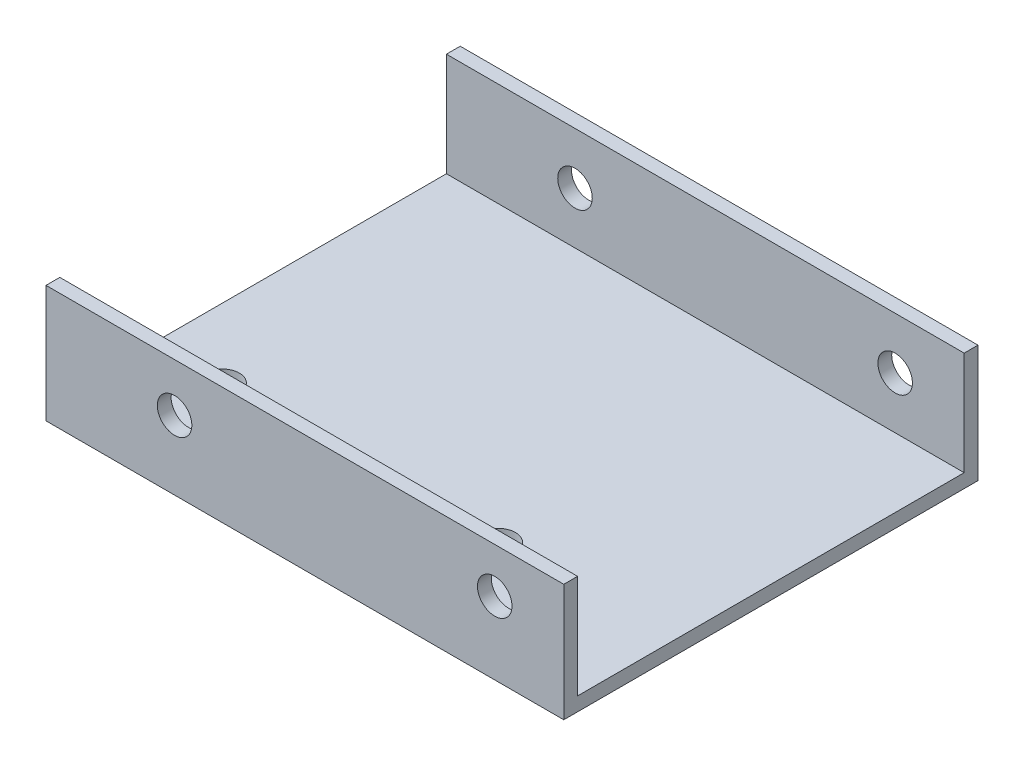
from build123d import *

# Parameters (mm, degrees)
ESBO_O1_W                = 75
ESBO_O1_H                = 56
RESSALTO_EXTRUS_O1_DEPTH = 2
ESBO_O3_W                = 75
ESBO_O3_H                = 17
RESSALTO_EXTRUS_O3_DEPTH = 2
CORTE_EXTRUS_O1_REACH    = 72
ESBO_O4_R                = 2.5
CORTE_EXTRUS_O2_REACH    = 62
ESBO_O5_R                = 2.5
ESBO_O6_R                = 2.5
CORTE_EXTRUS_O3_DEPTH    = 2
CUT_EXTRUDE1_REACH       = 62
SKETCH1_R                = 2.5
CUT_EXTRUDE2_REACH       = 62
SKETCH2_R                = 2.5


with BuildPart() as part:
    # Esboço1 → Ressalto-extrusão1 (new body)
    with BuildSketch(Plane(origin=(0, 0, 0), x_dir=(1, 0, 0), z_dir=(0, 1, 0))):
        Rectangle(ESBO_O1_W, ESBO_O1_H)
    extrude(amount=RESSALTO_EXTRUS_O1_DEPTH)

    # Esboço3 → Ressalto-extrusão3 (add)
    with BuildSketch(Plane.XY.offset(28)):
        with Locations((0, 8.5)):
            Rectangle(ESBO_O3_W, ESBO_O3_H)
    ressalto_extrus_o3 = extrude(amount=RESSALTO_EXTRUS_O3_DEPTH)

    # Espelhar2: Ressalto-extrusão3 across plane
    add(ressalto_extrus_o3.mirror(Plane.XY))

    # Esboço4 → Corte-extrusão1 (cut, up to next)
    with BuildSketch(Plane.XY.offset(40), mode=Mode.PRIVATE) as corte_extrus_o1_sk1:
        with Locations((-18.875, 10)):
            Circle(ESBO_O4_R)
    corte_extrus_o1_tool1 = extrude(corte_extrus_o1_sk1.sketch, amount=-CORTE_EXTRUS_O1_REACH, mode=Mode.PRIVATE) & part.part
    add(corte_extrus_o1_tool1.solids().sort_by_distance((-18.875, 10, 40))[0], mode=Mode.SUBTRACT)

    # Esboço5 → Corte-extrusão2 (cut, up to next)
    with BuildSketch(Plane.XY.offset(30), mode=Mode.PRIVATE) as corte_extrus_o2_sk1:
        with Locations((27.5, 10.5)):
            Circle(ESBO_O5_R)
    corte_extrus_o2_tool1 = extrude(corte_extrus_o2_sk1.sketch, amount=-CORTE_EXTRUS_O2_REACH, mode=Mode.PRIVATE) & part.part
    add(corte_extrus_o2_tool1.solids().sort_by_distance((27.5, 10.5, 30))[0], mode=Mode.SUBTRACT)

    # Esboço6 → Corte-extrusão3 (cut)
    with BuildSketch(Plane.XZ):
        with Locations((12.5, 14.5)):
            Circle(ESBO_O6_R)
        with Locations((-27.5, 14.5)):
            Circle(ESBO_O6_R)
    extrude(amount=-CORTE_EXTRUS_O3_DEPTH, mode=Mode.SUBTRACT)

    # Sketch1 → Cut-Extrude1 (cut, up to next)
    with BuildSketch(Plane(origin=(0, 0, -30), x_dir=(-1, 0, 0), z_dir=(0, 0, -1)), mode=Mode.PRIVATE) as cut_extrude1_sk1:
        with Locations((-27.5, 9.5)):
            Circle(SKETCH1_R)
    cut_extrude1_tool1 = extrude(cut_extrude1_sk1.sketch, amount=-CUT_EXTRUDE1_REACH, mode=Mode.PRIVATE) & part.part
    add(cut_extrude1_tool1.solids().sort_by_distance((27.5, 9.5, -30))[0], mode=Mode.SUBTRACT)

    # Sketch2 → Cut-Extrude2 (cut, up to next)
    with BuildSketch(Plane(origin=(0, 0, -30), x_dir=(-1, 0, 0), z_dir=(0, 0, -1)), mode=Mode.PRIVATE) as cut_extrude2_sk1:
        with Locations((18.875, 9.5)):
            Circle(SKETCH2_R)
    cut_extrude2_tool1 = extrude(cut_extrude2_sk1.sketch, amount=-CUT_EXTRUDE2_REACH, mode=Mode.PRIVATE) & part.part
    add(cut_extrude2_tool1.solids().sort_by_distance((-18.875, 9.5, -30))[0], mode=Mode.SUBTRACT)


solid = part.part
